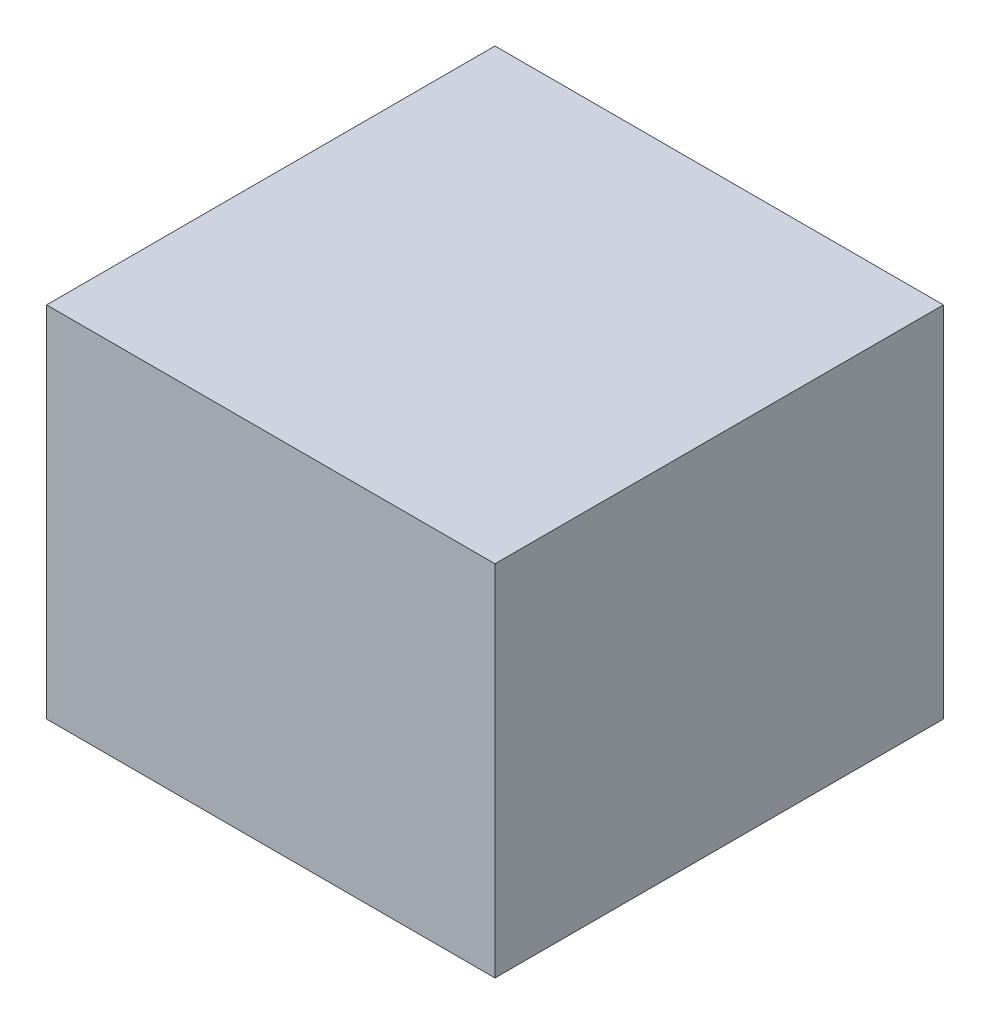
from build123d import *

# Parameters (mm, degrees)
SKETCH1_W      = 100
SKETCH1_H      = 100
EXTRUDE1_DEPTH = 80


with BuildPart() as part:
    # Sketch1 → Extrude1 (new body)
    with BuildSketch(Plane(origin=(0, 0, 0), x_dir=(1, 0, 0), z_dir=(0, 1, 0))):
        with Locations((50, 50)):
            Rectangle(SKETCH1_W, SKETCH1_H)
    extrude(amount=EXTRUDE1_DEPTH)


solid = part.part
